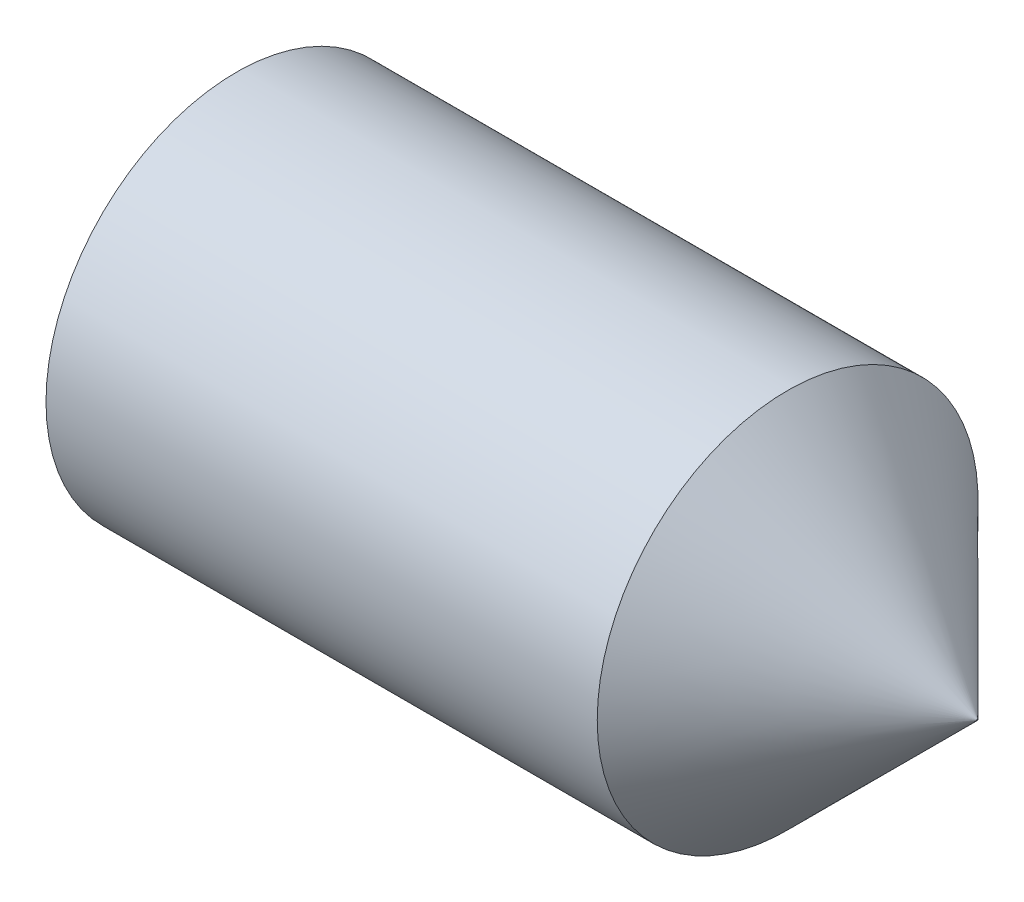
from build123d import *

# Parameters (mm, degrees)
HEX_2_DEPTH = 2


with BuildPart() as part:
    # BodySke → BaseBody (revolve)
    with BuildSketch(Plane.XY):
        Polygon((0, 0), (0, 1.2195), (0.161946751, 1.5), (4.505, 1.5), (6, 0.005), (6, 0), align=None)
    revolve(axis=Axis((-12.7, 0, 0), (1, 0, 0)))

    # Sketch2 → Hex 2 (cut)
    with BuildSketch(Plane.ZY):
        Polygon((0.433012702, 0.75), (-0.433012702, 0.75), (-0.866025404, 0), (-0.433012702, -0.75), (0.433012702, -0.75), (0.866025404, 0), align=None)
    extrude(amount=-HEX_2_DEPTH, mode=Mode.SUBTRACT)


solid = part.part
